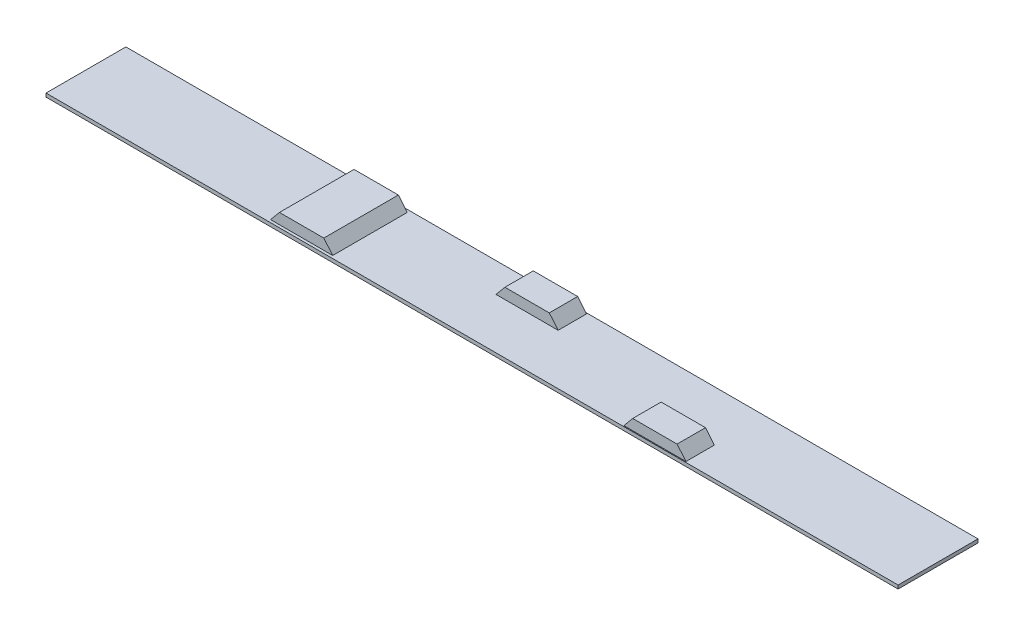
from build123d import *

# Parameters (mm, degrees)
SKETCH1_W                = 2400
SKETCH1_H                = 225
BOSS_EXTRUDE1_DEPTH      = 10
BOSS_EXTRUDE4_START      = 30
BOSS_EXTRUDE4_DEPTH      = 80
BOSS_EXTRUDE5_START      = -30
BOSS_EXTRUDE5_DEPTH      = 80
BOSS_EXTRUDE6_DEPTH      = 105
BOSS_EXTRUDE6_DEPTH_BACK = 105


with BuildPart() as part:
    # Sketch1 → Boss-Extrude1 (new body)
    with BuildSketch(Plane(origin=(0, 0, 0), x_dir=(1, 0, 0), z_dir=(0, 1, 0))):
        Rectangle(SKETCH1_W, SKETCH1_H)
    extrude(amount=BOSS_EXTRUDE1_DEPTH)

    # Sketch8 → Boss-Extrude4 (add)
    with BuildSketch(Plane.XY.offset(BOSS_EXTRUDE4_START)):
        Polygon((425, 10), (450, 40), (575, 40), (600, 10), align=None)
    extrude(amount=BOSS_EXTRUDE4_DEPTH)

    # Sketch14 → Boss-Extrude5 (add)
    with BuildSketch(Plane.XY.offset(BOSS_EXTRUDE5_START)):
        Polygon((-75, 10), (100, 10), (75, 40), (-50, 40), align=None)
    extrude(amount=-BOSS_EXTRUDE5_DEPTH)

    # Sketch15 → Boss-Extrude6 (add, two sides)
    with BuildSketch(Plane.XY) as boss_extrude6_sk:
        Polygon((-400, 10), (-425, 40), (-550, 40), (-575, 10), align=None)
    extrude(amount=BOSS_EXTRUDE6_DEPTH)
    extrude(boss_extrude6_sk.sketch, amount=-BOSS_EXTRUDE6_DEPTH_BACK)


solid = part.part
